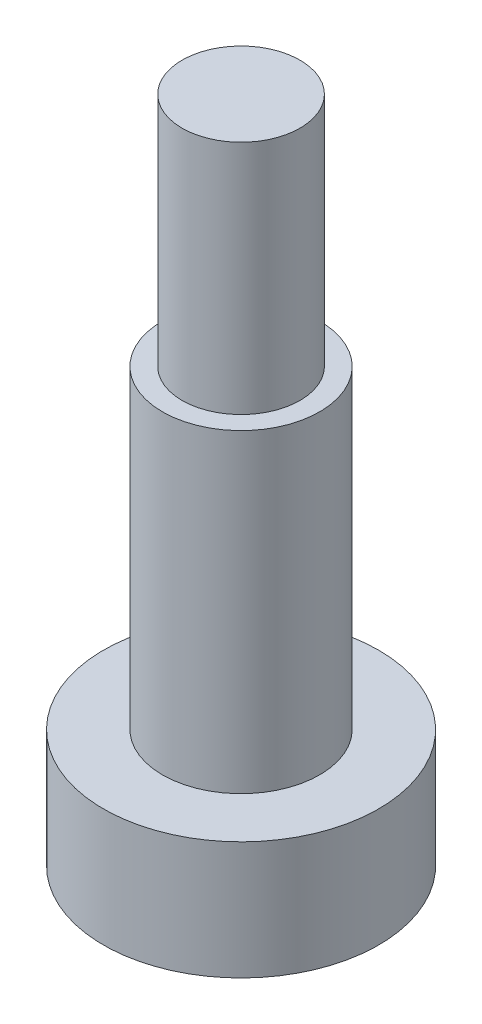
from build123d import *

# Parameters (mm, degrees)
SKETCH_1_R      = 2
EXTRUDE_1_DEPTH = 8
SKETCH_2_R      = 1.5
EXTRUDE_2_DEPTH = 6
SKETCH_3_R      = 3.5
EXTRUDE_3_DEPTH = 3


with BuildPart() as part:
    # 草图1 → 凸台-拉伸1 (new body)
    with BuildSketch(Plane(origin=(0, 0, 0), x_dir=(1, 0, 0), z_dir=(0, 1, 0))):
        Circle(SKETCH_1_R)
    extrude(amount=EXTRUDE_1_DEPTH)

    # 草图2 → 凸台-拉伸2 (add)
    with BuildSketch(Plane(origin=(0, 8, 0), x_dir=(1, 0, 0), z_dir=(0, 1, 0))):
        Circle(SKETCH_2_R)
    extrude(amount=EXTRUDE_2_DEPTH)

    # 草图3 → 凸台-拉伸3 (add)
    with BuildSketch(Plane.XZ):
        Circle(SKETCH_3_R)
    extrude(amount=EXTRUDE_3_DEPTH)


solid = part.part
